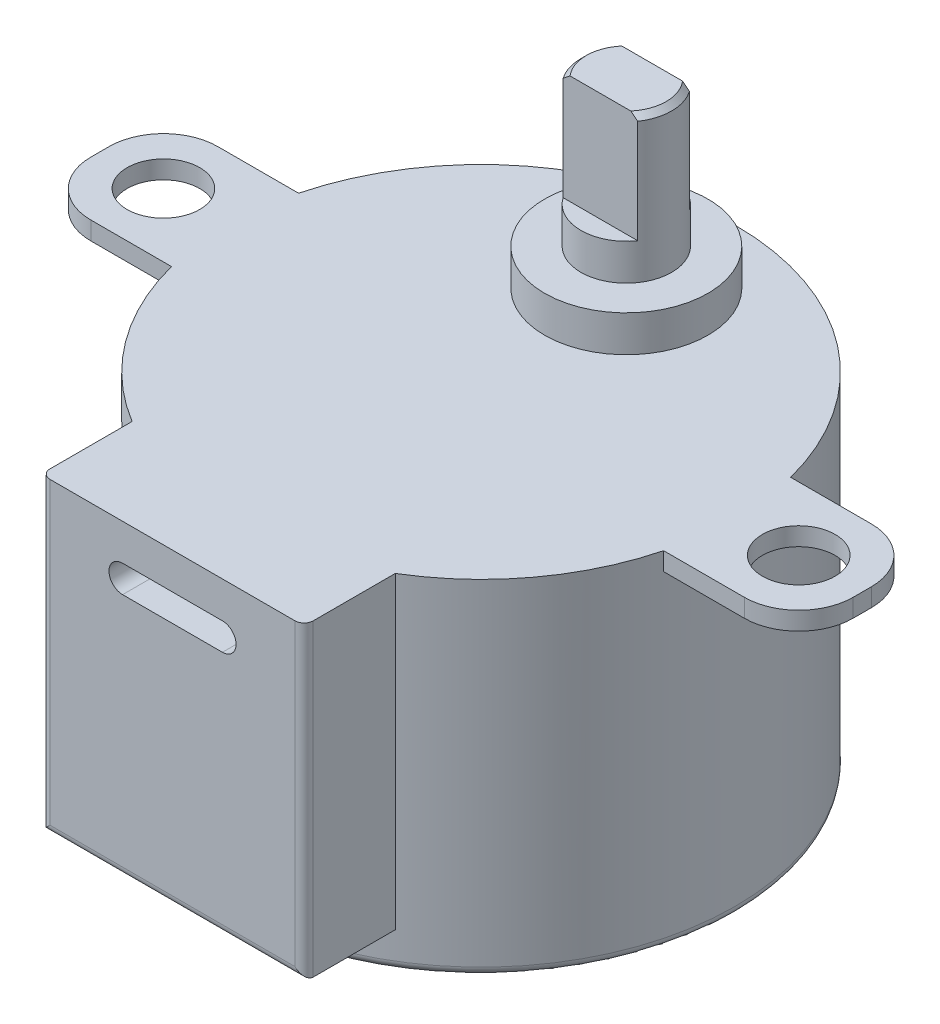
from build123d import *

# Parameters (mm, degrees)
SKETCH_1_R          = 14
EXTRUDE_1_DEPTH     = 19
SKETCH_2_R          = 2
EXTRUDE_2_DEPTH     = 1
EXTRUDE_3_DEPTH     = 17
SKETCH_6_R          = 4.5
EXTRUDE_4_DEPTH     = 2
SKETCH_7_R          = 2.5
EXTRUDE_6_DEPTH     = 2
EXTRUDE_8_DEPTH     = 6
CUT_EXTRUDE_1_DEPTH = 2
CHAMFER_4_SIZE      = 0.3
FILLET_3_R          = 0.5
FILLET_4_R          = 0.5


with BuildPart() as part:
    # Эскиз1 → Бобышка-Вытянуть1 (new body)
    with BuildSketch(Plane(origin=(0, 0, 0), x_dir=(1, 0, 0), z_dir=(0, 1, 0))):
        with Locations(Location((0, 0, 0), (0, 0, 270))):
            Circle(SKETCH_1_R)
    extrude(amount=EXTRUDE_1_DEPTH)

    # Эскиз2 → Бобышка-Вытянуть2 (add)
    with BuildSketch(Plane(origin=(0, 19, 0), x_dir=(1, 0, 0), z_dir=(0, 1, 0))):
        with BuildLine():
            ThreePointArc((14, 0), (13.888415748, -1.764060095), (13.555441712, -3.5))
            Line((13.555441712, -3.5), (18, -3.5))
            ThreePointArc((18, -3.5), (20.121320344, -2.621320344), (21, -0.5))
            Line((21, -0.5), (21, 0.5))
            ThreePointArc((21, 0.5), (20.121320344, 2.621320344), (18, 3.5))
            Line((18, 3.5), (13.555441712, 3.5))
            ThreePointArc((13.555441712, 3.5), (13.888415748, 1.764060095), (14, 0))
        make_face()
        with Locations(Location((17.5, 0, 0), (0, 0, 270))):
            Circle(SKETCH_2_R, mode=Mode.SUBTRACT)
        with BuildLine():
            ThreePointArc((-21, -0.5), (-20.121320344, -2.621320344), (-18, -3.5))
            Line((-18, -3.5), (-13.555441712, -3.5))
            ThreePointArc((-13.555441712, -3.5), (-14, 0), (-13.555441712, 3.5))
            Line((-13.555441712, 3.5), (-18, 3.5))
            ThreePointArc((-18, 3.5), (-20.121320344, 2.621320344), (-21, 0.5))
            Line((-21, 0.5), (-21, -0.5))
        make_face()
        with Locations(Location((-17.5, 0, 0), (0, 0, 270))):
            Circle(SKETCH_2_R, mode=Mode.SUBTRACT)
    extrude(amount=-EXTRUDE_2_DEPTH)

    # Эскиз5 → Бобышка-Вытянуть3 (add)
    with BuildSketch(Plane(origin=(0, 19, 0), x_dir=(1, 0, 0), z_dir=(0, 1, 0))):
        with BuildLine():
            Line((-7.25, -17), (7.25, -17))
            Line((7.25, -17), (7.25, -11.976539567))
            ThreePointArc((7.25, -11.976539567), (0, -14), (-7.25, -11.976539567))
            Line((-7.25, -11.976539567), (-7.25, -17))
        make_face()
    extrude(amount=-EXTRUDE_3_DEPTH)

    # Эскиз6 → Бобышка-Вытянуть4 (add)
    with BuildSketch(Plane(origin=(0, 19, 0), x_dir=(1, 0, 0), z_dir=(0, 1, 0))):
        with Locations(Location((0, 8, 0), (0, 0, 270))):
            Circle(SKETCH_6_R)
    extrude(amount=EXTRUDE_4_DEPTH)

    # Эскиз7 → Бобышка-Вытянуть6 (add)
    with BuildSketch(Plane(origin=(0, 21, 0), x_dir=(1, 0, 0), z_dir=(0, 1, 0))):
        with Locations(Location((0, 8, 0), (0, 0, 270))):
            Circle(SKETCH_7_R)
    extrude(amount=EXTRUDE_6_DEPTH)

    # Эскиз9 → Бобышка-Вытянуть8 (add)
    with BuildSketch(Plane(origin=(0, 23, 0), x_dir=(1, 0, 0), z_dir=(0, 1, 0))):
        with BuildLine():
            Line((-2.053041545, 9.426541417), (2.053041545, 9.426541417))
            ThreePointArc((2.053041545, 9.426541417), (2.5, 8), (2.053041545, 6.573458583))
            Line((2.053041545, 6.573458583), (-2.053041545, 6.573458583))
            ThreePointArc((-2.053041545, 6.573458583), (-2.5, 8), (-2.053041545, 9.426541417))
        make_face()
    extrude(amount=EXTRUDE_8_DEPTH)

    # Эскиз11 → Вырез-Вытянуть1 (cut)
    with BuildSketch(Plane.XY.offset(17)):
        with BuildLine():
            Line((-2.75, 17), (2.75, 17))
            ThreePointArc((2.75, 17), (3.5, 16.25), (2.75, 15.5))
            Line((2.75, 15.5), (-2.75, 15.5))
            ThreePointArc((-2.75, 15.5), (-3.5, 16.25), (-2.75, 17))
        make_face()
    extrude(amount=-CUT_EXTRUDE_1_DEPTH, mode=Mode.SUBTRACT)

    # Фаска4
    chamfer_4_edges = [part.edges().sort_by_distance(p)[0] for p in [
        (2.5, 29, -8),
        (-2.5, 29, -8),
    ]]
    chamfer(chamfer_4_edges, length=CHAMFER_4_SIZE)

    # Скругление3
    fillet_3_edges = [part.edges().sort_by_distance(p)[0] for p in [
        (0, 2, 17),
        (7.25, 10.5, 17),
        (-7.25, 10.5, 17),
    ]]
    fillet(fillet_3_edges, radius=FILLET_3_R)

    # Скругление4
    fillet_4_edges = [part.edges().sort_by_distance(p)[0] for p in [
        (0, 0, -14),
    ]]
    fillet(fillet_4_edges, radius=FILLET_4_R)


solid = part.part
